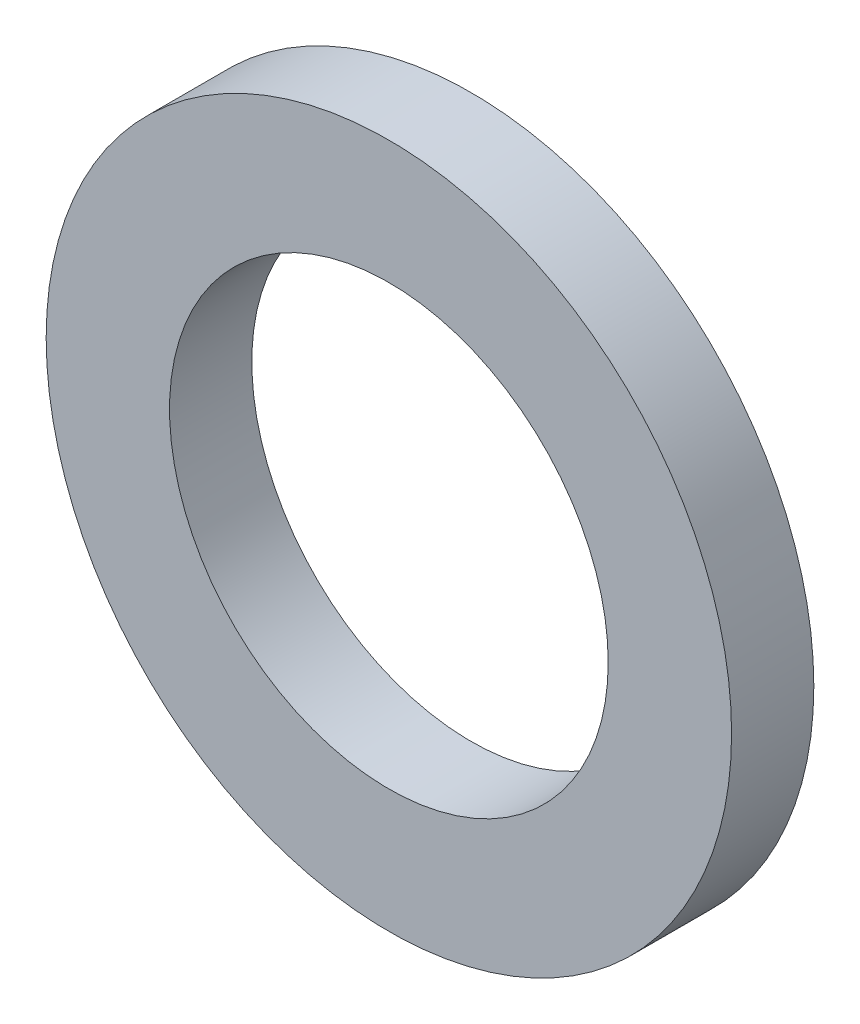
from build123d import *

# Parameters (mm, degrees)
SKETCH1_R           = 6.25
SKETCH1_R_2         = 4
BOSS_EXTRUDE1_DEPTH = 1.5


with BuildPart() as part:
    # Sketch1 → Boss-Extrude1 (new body)
    with BuildSketch(Plane.XY):
        Circle(SKETCH1_R)
        Circle(SKETCH1_R_2, mode=Mode.SUBTRACT)
    extrude(amount=BOSS_EXTRUDE1_DEPTH)


solid = part.part
